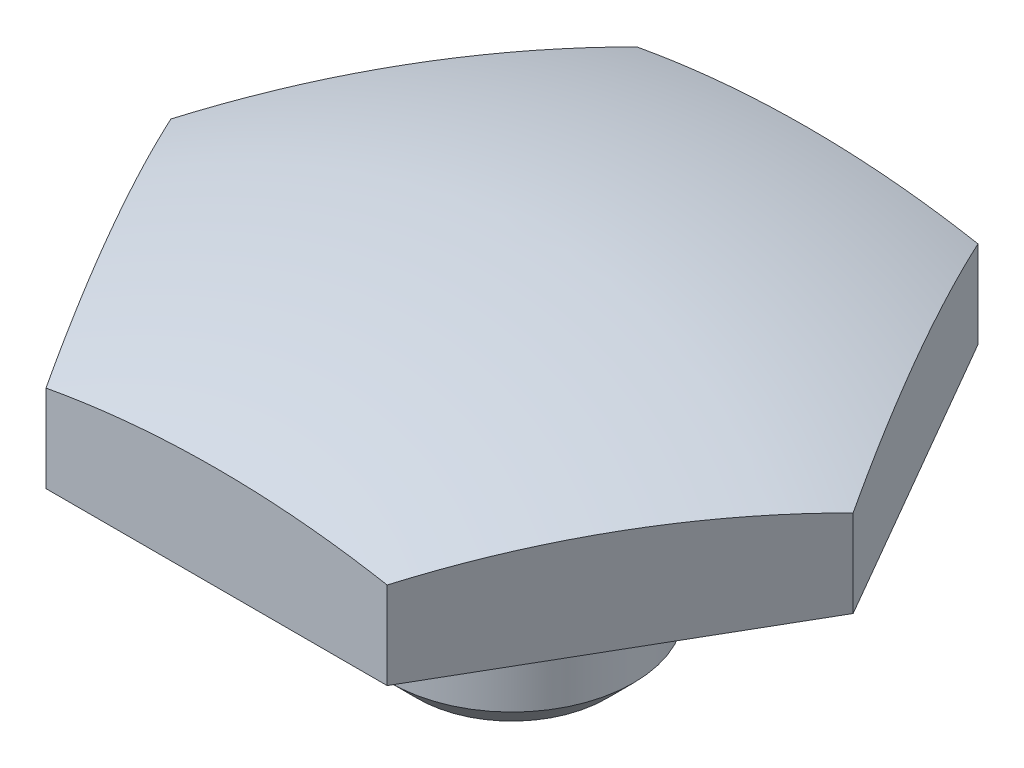
from build123d import *

# Parameters (mm, degrees)
CUT_EXTRUDE2_DEPTH = 11.1252


with BuildPart() as part:
    # Sketch3 → Revolve1 (revolve)
    with BuildSketch(Plane.XY):
        with BuildLine():
            Line((3.9116, 3.5052), (3.9116, 0.8636))
            Line((3.9116, 0.8636), (3.048, 0))
            Line((3.048, 0), (0, 0))
            Line((0, 0), (0, 11.1252))
            ThreePointArc((0, 11.1252), (5.586411751, 10.629871711), (10.9985175, 9.159341969))
            Line((10.9985175, 9.159341969), (10.9985175, 6.35))
            Line((10.9985175, 6.35), (3.429, 6.35))
            ThreePointArc((3.429, 6.35), (3.159592316, 6.238407684), (3.048, 5.969))
            Line((3.048, 5.969), (3.048, 4.3688))
            Line((3.048, 4.3688), (3.9116, 3.5052))
        make_face()
    revolve(axis=Axis((0, -1000, 0), (0, 1, 0)))

    # Sketch1 → Cut-Extrude2 (cut)
    with BuildSketch(Plane(origin=(0, 0, 0), x_dir=(1, 0, 0), z_dir=(0, 1, 0))):
        with BuildLine():
            ThreePointArc((-5.499261314, -9.525), (0, -10.998522628), (5.499261314, -9.525))
            Line((5.499261314, -9.525), (-5.499261314, -9.525))
        make_face()
        with BuildLine():
            ThreePointArc((-10.998522628, 0), (-9.525, -5.499261314), (-5.499261314, -9.525))
            Line((-5.499261314, -9.525), (-10.998522628, 0))
        make_face()
        with BuildLine():
            ThreePointArc((5.499261314, -9.525), (9.525, -5.499261314), (10.998522628, 0))
            Line((10.998522628, 0), (5.499261314, -9.525))
        make_face()
        with BuildLine():
            Line((5.499261314, 9.525), (10.998522628, 0))
            ThreePointArc((10.998522628, 0), (9.525, 5.499261314), (5.499261314, 9.525))
        make_face()
        with BuildLine():
            Line((-5.499261314, 9.525), (5.499261314, 9.525))
            ThreePointArc((5.499261314, 9.525), (0, 10.998522628), (-5.499261314, 9.525))
        make_face()
        with BuildLine():
            Line((-10.998522628, 0), (-5.499261314, 9.525))
            ThreePointArc((-5.499261314, 9.525), (-9.525, 5.499261314), (-10.998522628, 0))
        make_face()
    extrude(amount=CUT_EXTRUDE2_DEPTH, mode=Mode.SUBTRACT)


solid = part.part
